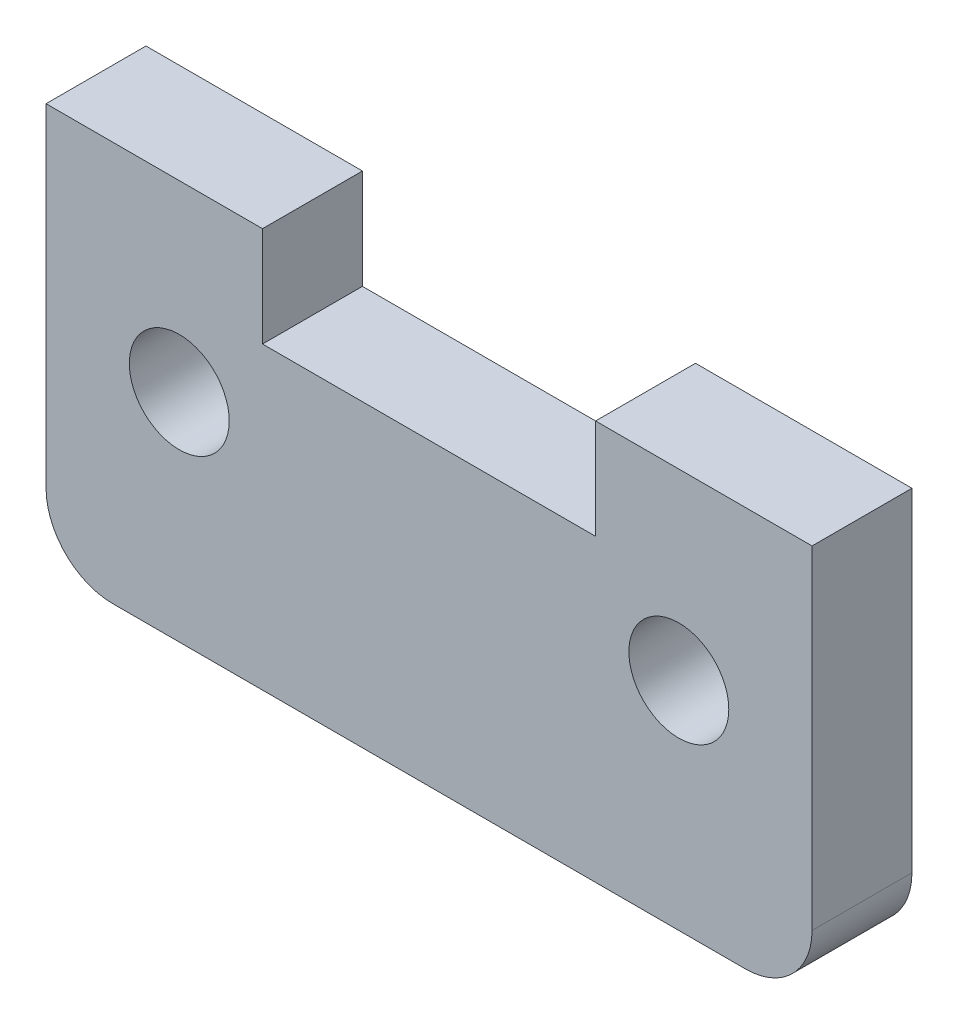
from build123d import *

# Parameters (mm, degrees)
SKETCH1_R           = 1.5
BOSS_EXTRUDE1_DEPTH = 3


with BuildPart() as part:
    # Sketch1 → Boss-Extrude1 (new body)
    with BuildSketch(Plane.XY):
        with BuildLine():
            Line((-10.322941477, 5.588109805), (-10.322941477, 2.588109805))
            Line((-10.322941477, 2.588109805), (-0.322941477, 2.588109805))
            Line((-0.322941477, 2.588109805), (-0.322941477, 5.588109805))
            Line((-0.322941477, 5.588109805), (6.177058523, 5.588109805))
            Line((6.177058523, 5.588109805), (6.177058523, -4.411890195))
            ThreePointArc((6.177058523, -4.411890195), (5.591272086, -5.826103757), (4.177058523, -6.411890195))
            Line((4.177058523, -6.411890195), (-14.822941477, -6.411890195))
            ThreePointArc((-14.822941477, -6.411890195), (-16.237155039, -5.826103757), (-16.822941477, -4.411890195))
            Line((-16.822941477, -4.411890195), (-16.822941477, 5.588109805))
            Line((-16.822941477, 5.588109805), (-10.322941477, 5.588109805))
        make_face()
        with Locations((-12.822941477, 0.088109805)):
            Circle(SKETCH1_R, mode=Mode.SUBTRACT)
        with Locations((2.177058523, 0.088109805)):
            Circle(SKETCH1_R, mode=Mode.SUBTRACT)
    extrude(amount=BOSS_EXTRUDE1_DEPTH)


solid = part.part
